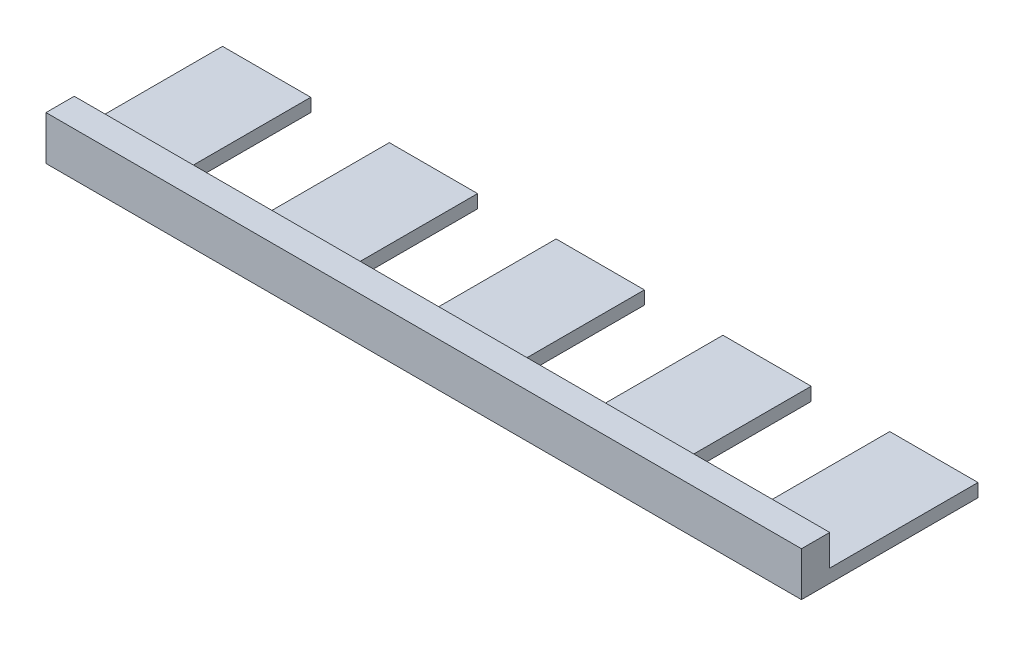
from build123d import *

# Parameters (mm, degrees)
SKIZZE1_W                       = 20
SKIZZE1_H                       = 33.6
AUFSATZ_LINEAR_AUSTRAGEN1_DEPTH = 3
SKIZZE3_W                       = 171.2
SKIZZE3_H                       = 6.4
AUFSATZ_LINEAR_AUSTRAGEN2_DEPTH = 7


with BuildPart() as part:
    # Skizze1 → Aufsatz-Linear austragen1 (new body)
    with BuildSketch(Plane(origin=(0, 0, 0), x_dir=(1, 0, 0), z_dir=(0, 1, 0))):
        with Locations((10, 23.2)):
            Rectangle(SKIZZE1_W, SKIZZE1_H)
        Polygon((0, 6.4), (0, 0), (171.2, 0), (171.2, 40), (151.2, 40), (151.2, 6.4), (133.4, 6.4), (133.4, 40), (113.4, 40), (113.4, 6.4), (95.6, 6.4), (95.6, 40), (75.6, 40), (75.6, 6.4), (57.8, 6.4), (57.8, 40), (37.8, 40), (37.8, 6.4), (20, 6.4), align=None)
    extrude(amount=AUFSATZ_LINEAR_AUSTRAGEN1_DEPTH)

    # Skizze3 → Aufsatz-Linear austragen2 (add)
    with BuildSketch(Plane(origin=(0, 3, 0), x_dir=(1, 0, 0), z_dir=(0, 1, 0))):
        with Locations((85.6, 3.2)):
            Rectangle(SKIZZE3_W, SKIZZE3_H)
    extrude(amount=AUFSATZ_LINEAR_AUSTRAGEN2_DEPTH)


solid = part.part
